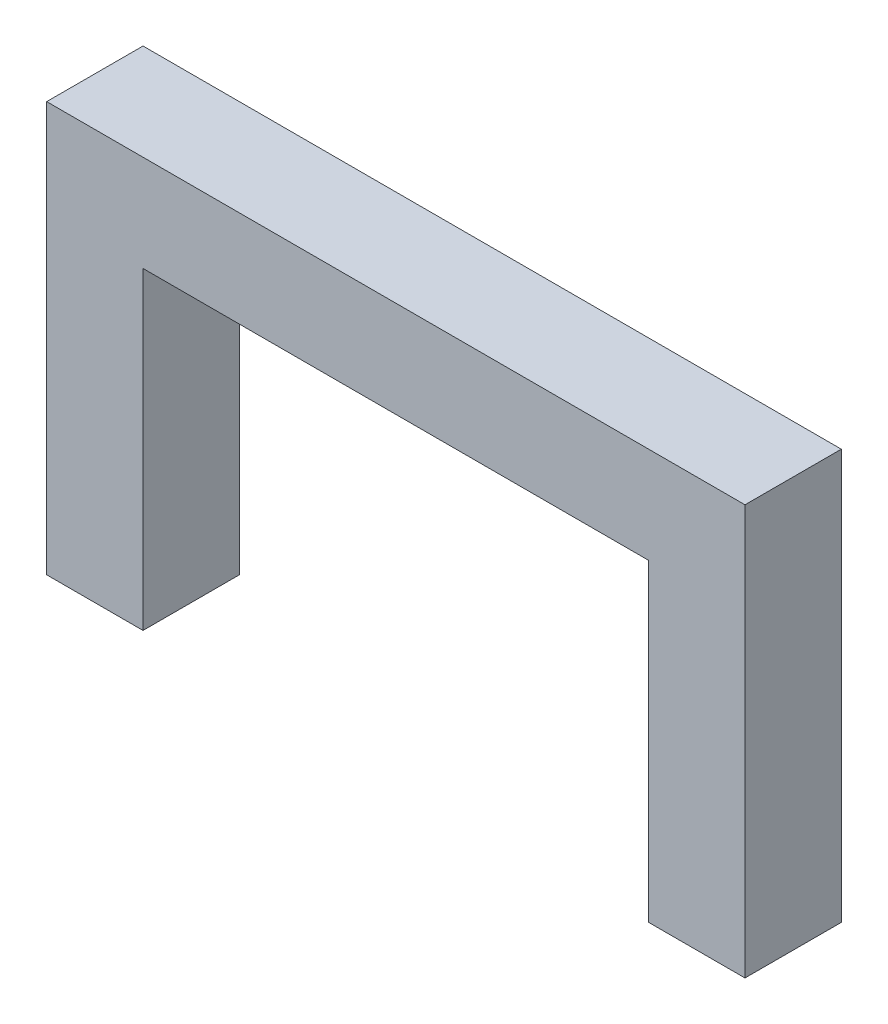
from build123d import *

# Parameters (mm, degrees)
SKETCH2_W             = 19.05
SKETCH2_H             = 19.05
BOSS_EXTRUDE1_DEPTH   = 62
BOSS_EXTRUDE1_2_DEPTH = 62
SKETCH3_W             = 138.1
SKETCH3_H             = 19.05
BOSS_EXTRUDE2_DEPTH   = 19.05


with BuildPart() as part:
    # Sketch2 → Boss-Extrude1 (new body)
    with BuildSketch(Plane(origin=(0, 0, 0), x_dir=(1, 0, 0), z_dir=(0, 1, 0))):
        with Locations((9.525, -9.525)):
            Rectangle(SKETCH2_W, SKETCH2_H)
    extrude(amount=BOSS_EXTRUDE1_DEPTH)



with BuildPart() as body_2:
    # Sketch2 → Boss-Extrude1 2 (new body)
    with BuildSketch(Plane(origin=(0, 0, 0), x_dir=(1, 0, 0), z_dir=(0, 1, 0))):
        with Locations((128.575, -9.525)):
            Rectangle(SKETCH2_W, SKETCH2_H)
    extrude(amount=BOSS_EXTRUDE1_2_DEPTH)


with BuildPart() as part_1:
    add(part.part)

    add(body_2.part)  # Boss-Extrude2 merges body 2
    # Sketch3 → Boss-Extrude2 (add)
    with BuildSketch(Plane(origin=(0, 62, 0), x_dir=(1, 0, 0), z_dir=(0, 1, 0))):
        with Locations((69.05, -9.525)):
            Rectangle(SKETCH3_W, SKETCH3_H)
    extrude(amount=BOSS_EXTRUDE2_DEPTH)


solid = part_1.part
